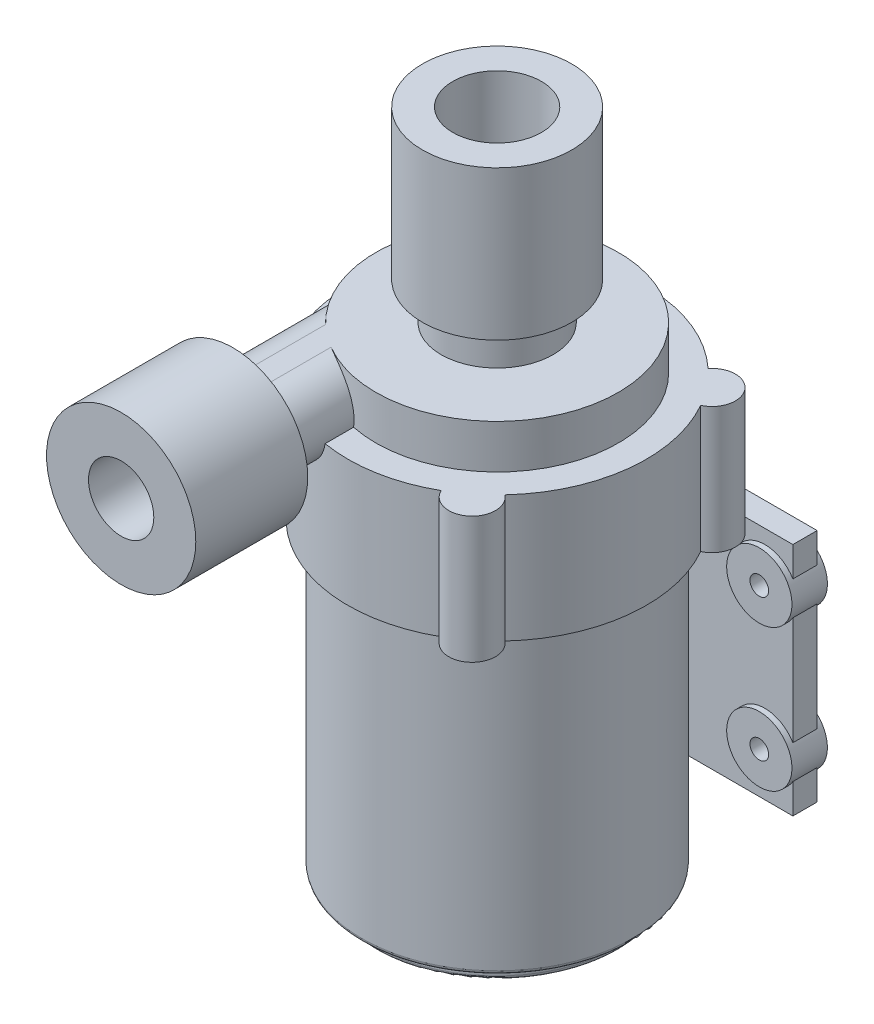
from build123d import *

# Parameters (mm, degrees)
SKETCH1_R            = 18.415
BOSS_EXTRUDE1_DEPTH  = 42.672
SKETCH2_OUTSIDE_W    = 52.296
SKETCH2_OUTSIDE_H    = 52.296
SKETCH2_OUTSIDE_R    = 16.51
CUT_EXTRUDE2_DEPTH   = 1.9431
FILLET1_R            = 0.508
SKETCH3_W            = 45.212
SKETCH3_H            = 32.004
SKETCH3_R            = 1.27
BOSS_EXTRUDE2_DEPTH  = 2.54
SKETCH3_2_W          = 45.212
SKETCH3_2_H          = 32.004
SKETCH3_2_R          = 1.27
BOSS_EXTRUDE3_DEPTH  = 0.762
SKETCH5_R            = 4.445
SKETCH5_R_2          = 1.27
BOSS_EXTRUDE5_DEPTH  = 0.762
SKETCH5_4_R          = 4.445
SKETCH5_4_R_2        = 1.27
BOSS_EXTRUDE8_DEPTH  = 4.064
BOSS_EXTRUDE9_DEPTH  = 17.2339
SKETCH7_R            = 16.51
BOSS_EXTRUDE10_DEPTH = 5.969
SKETCH8_R            = 7.62
BOSS_EXTRUDE11_DEPTH = 5.08
SKETCH9_R            = 10.16
SKETCH9_R_2          = 6.0325
BOSS_EXTRUDE12_DEPTH = 20.32
BOSS_EXTRUDE13_START = -16.51
BOSS_EXTRUDE13_DEPTH = 16.51
BOSS_EXTRUDE14_DEPTH = 9.525
SKETCH11_R           = 10.16
SKETCH11_R_2         = 4.445
BOSS_EXTRUDE17_DEPTH = 15.24


with BuildPart() as part:
    # Sketch1 → Boss-Extrude1 (new body)
    with BuildSketch(Plane(origin=(0, 0, 0), x_dir=(1, 0, 0), z_dir=(0, 1, 0))):
        Circle(SKETCH1_R)
    extrude(amount=BOSS_EXTRUDE1_DEPTH)

    # Sketch2 outside → Cut-Extrude2 (cut)
    with BuildSketch(Plane.XZ):
        Rectangle(SKETCH2_OUTSIDE_W, SKETCH2_OUTSIDE_H)
        Circle(SKETCH2_OUTSIDE_R, mode=Mode.SUBTRACT)
    extrude(amount=-CUT_EXTRUDE2_DEPTH, mode=Mode.SUBTRACT)

    # Fillet1
    fillet1_edges = [part.edges().sort_by_distance(p)[0] for p in [
        (-16.51, 0, 0),
        (-16.51, 1.9431, 0),
        (-18.415, 1.9431, 0),
    ]]
    fillet(fillet1_edges, radius=FILLET1_R)



with BuildPart() as body_2:
    # Sketch3 → Boss-Extrude2 (new body)
    with BuildSketch(Plane(origin=(0, 0, -18.415), x_dir=(-1, 0, 0), z_dir=(0, 0, -1))):
        with Locations((0, 26.162)):
            Rectangle(SKETCH3_W, SKETCH3_H)
        with Locations((-18.796, 35.814)):
            Circle(SKETCH3_R, mode=Mode.SUBTRACT)
        with Locations((-18.796, 16.51)):
            Circle(SKETCH3_R, mode=Mode.SUBTRACT)
        with Locations((18.796, 16.51)):
            Circle(SKETCH3_R, mode=Mode.SUBTRACT)
        with Locations((18.796, 35.814)):
            Circle(SKETCH3_R, mode=Mode.SUBTRACT)
    extrude(amount=BOSS_EXTRUDE2_DEPTH)


with BuildPart() as part_1:
    add(part.part)

    add(body_2.part)  # Boss-Extrude3 merges body 2
    # Sketch3_2 → Boss-Extrude3 (add)
    with BuildSketch(Plane(origin=(0, 0, -18.415), x_dir=(-1, 0, 0), z_dir=(0, 0, -1))):
        with Locations((0, 26.162)):
            Rectangle(SKETCH3_2_W, SKETCH3_2_H)
        with Locations((-18.796, 35.814)):
            Circle(SKETCH3_2_R, mode=Mode.SUBTRACT)
        with Locations((-18.796, 16.51)):
            Circle(SKETCH3_2_R, mode=Mode.SUBTRACT)
        with Locations((18.796, 16.51)):
            Circle(SKETCH3_2_R, mode=Mode.SUBTRACT)
        with Locations((18.796, 35.814)):
            Circle(SKETCH3_2_R, mode=Mode.SUBTRACT)
    extrude(amount=-BOSS_EXTRUDE3_DEPTH)

    # Sketch5 → Boss-Extrude5 (add)
    with BuildSketch(Plane(origin=(0, 0, -20.955), x_dir=(-1, 0, 0), z_dir=(0, 0, -1))):
        with Locations((-18.796, 35.814)):
            Circle(SKETCH5_R)
        with Locations((-18.796, 35.814)):
            Circle(SKETCH5_R_2, mode=Mode.SUBTRACT)
        with Locations((-18.796, 16.51)):
            Circle(SKETCH5_R)
        with Locations((-18.796, 16.51)):
            Circle(SKETCH5_R_2, mode=Mode.SUBTRACT)
        with Locations((18.796, 16.51)):
            Circle(SKETCH5_R)
        with Locations((18.796, 16.51)):
            Circle(SKETCH5_R_2, mode=Mode.SUBTRACT)
        with Locations((18.796, 35.814)):
            Circle(SKETCH5_R)
        with Locations((18.796, 35.814)):
            Circle(SKETCH5_R_2, mode=Mode.SUBTRACT)
    extrude(amount=BOSS_EXTRUDE5_DEPTH)

    # Sketch5_4 → Boss-Extrude8 (add)
    with BuildSketch(Plane(origin=(0, 0, -20.955), x_dir=(-1, 0, 0), z_dir=(0, 0, -1))):
        with Locations((-18.796, 35.814)):
            Circle(SKETCH5_4_R)
        with Locations((-18.796, 35.814)):
            Circle(SKETCH5_4_R_2, mode=Mode.SUBTRACT)
        with Locations((-18.796, 16.51)):
            Circle(SKETCH5_4_R)
        with Locations((-18.796, 16.51)):
            Circle(SKETCH5_4_R_2, mode=Mode.SUBTRACT)
        with Locations((18.796, 16.51)):
            Circle(SKETCH5_4_R)
        with Locations((18.796, 16.51)):
            Circle(SKETCH5_4_R_2, mode=Mode.SUBTRACT)
        with Locations((18.796, 35.814)):
            Circle(SKETCH5_4_R)
        with Locations((18.796, 35.814)):
            Circle(SKETCH5_4_R_2, mode=Mode.SUBTRACT)
    extrude(amount=-BOSS_EXTRUDE8_DEPTH)

    # Sketch6 → Boss-Extrude9 (add)
    with BuildSketch(Plane(origin=(0, 42.672, 0), x_dir=(1, 0, 0), z_dir=(0, 1, 0))):
        with BuildLine():
            ThreePointArc((-14.885846945, 13.831628998), (-20.183913314, 2.347774127), (-17.663218531, -10.045551809))
            ThreePointArc((-17.663218531, -10.045551809), (-18.820039984, -14.897989932), (-13.831628998, -14.885846945))
            ThreePointArc((-13.831628998, -14.885846945), (-2.347774127, -20.183913314), (10.045551809, -17.663218531))
            ThreePointArc((10.045551809, -17.663218531), (14.897989932, -18.820039984), (14.885846945, -13.831628998))
            ThreePointArc((14.885846945, -13.831628998), (20.183913314, -2.347774127), (17.663218531, 10.045551809))
            ThreePointArc((17.663218531, 10.045551809), (18.820039984, 14.897989932), (13.831628998, 14.885846945))
            ThreePointArc((13.831628998, 14.885846945), (2.347774127, 20.183913314), (-10.045551809, 17.663218531))
            ThreePointArc((-10.045551809, 17.663218531), (-14.897989932, 18.820039984), (-14.885846945, 13.831628998))
        make_face()
    extrude(amount=BOSS_EXTRUDE9_DEPTH)

    # Sketch7 → Boss-Extrude10 (add)
    with BuildSketch(Plane(origin=(0, 59.9059, 0), x_dir=(1, 0, 0), z_dir=(0, 1, 0))):
        Circle(SKETCH7_R)
    extrude(amount=BOSS_EXTRUDE10_DEPTH)

    # Sketch8 → Boss-Extrude11 (add)
    with BuildSketch(Plane(origin=(0, 65.8749, 0), x_dir=(1, 0, 0), z_dir=(0, 1, 0))):
        Circle(SKETCH8_R)
    extrude(amount=BOSS_EXTRUDE11_DEPTH)

    # Sketch9 → Boss-Extrude12 (add)
    with BuildSketch(Plane(origin=(0, 70.9549, 0), x_dir=(1, 0, 0), z_dir=(0, 1, 0))):
        Circle(SKETCH9_R)
        Circle(SKETCH9_R_2, mode=Mode.SUBTRACT)
    extrude(amount=BOSS_EXTRUDE12_DEPTH)

    # Sketch10 → Boss-Extrude13 (add)
    with BuildSketch(Plane.XY.offset(16.51).offset(BOSS_EXTRUDE13_START)):
        with BuildLine():
            Line((-8.382, 65.8749), (-11.43, 65.8749))
            ThreePointArc((-11.43, 65.8749), (-16.51, 60.7949), (-11.43, 55.7149))
            Line((-11.43, 55.7149), (-8.382, 55.7149))
            ThreePointArc((-8.382, 55.7149), (-3.302, 60.7949), (-8.382, 65.8749))
        make_face()
    extrude(amount=BOSS_EXTRUDE13_DEPTH)

    # Sketch10_2 → Boss-Extrude14 (add)
    with BuildSketch(Plane.XY.offset(16.51)):
        with BuildLine():
            Line((-11.43, 65.8749), (-8.382, 65.8749))
            ThreePointArc((-8.382, 65.8749), (-3.302, 60.7949), (-8.382, 55.7149))
            Line((-8.382, 55.7149), (-11.43, 55.7149))
            ThreePointArc((-11.43, 55.7149), (-16.51, 60.7949), (-11.43, 65.8749))
        make_face()
    extrude(amount=BOSS_EXTRUDE14_DEPTH)

    # Sketch11 → Boss-Extrude17 (add)
    with BuildSketch(Plane.XY.offset(26.035)):
        with Locations((-9.906, 60.7949)):
            Circle(SKETCH11_R)
        with Locations((-9.906, 60.7949)):
            Circle(SKETCH11_R_2, mode=Mode.SUBTRACT)
    extrude(amount=BOSS_EXTRUDE17_DEPTH)


solid = part_1.part
